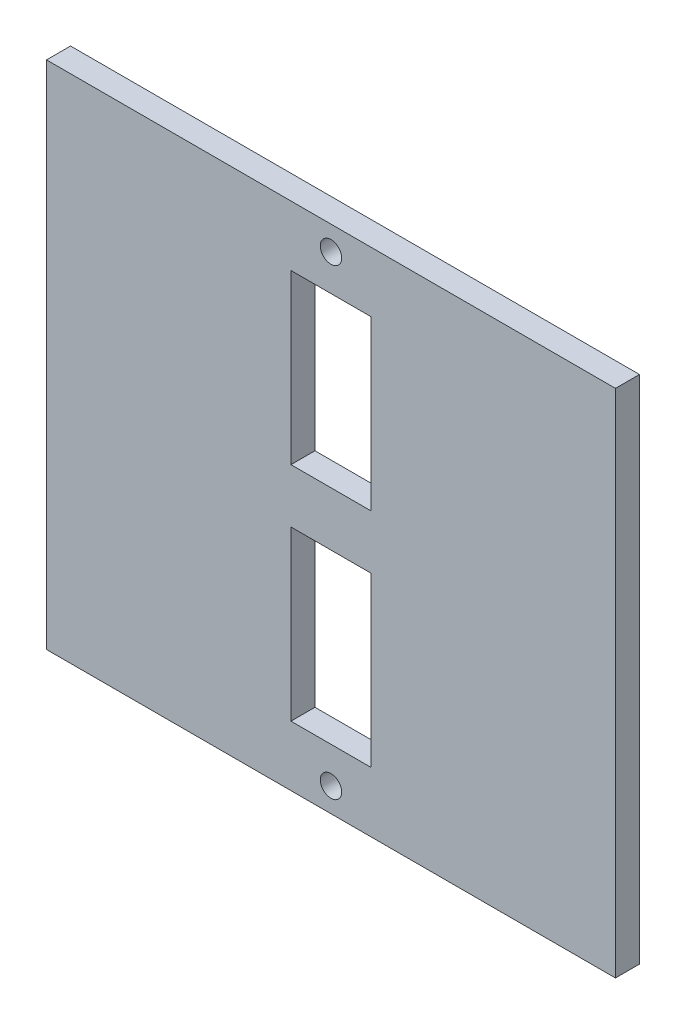
from build123d import *

# Parameters (mm, degrees)
SKETCH1_W           = 75.17
SKETCH1_H           = 67.47
SKETCH1_W_2         = 10.58
SKETCH1_H_2         = 22.218316852
BOSS_EXTRUDE1_DEPTH = 3.175
SKETCH2_R           = 1.415
CUT_EXTRUDE1_DEPTH  = 10


with BuildPart() as part:
    # Sketch1 → Boss-Extrude1 (new body)
    with BuildSketch(Plane.XY):
        Rectangle(SKETCH1_W, SKETCH1_H)
        with Locations((0, 14.675)):
            Rectangle(SKETCH1_W_2, SKETCH1_H_2, mode=Mode.SUBTRACT)
        with Locations((0, -14.675)):
            Rectangle(SKETCH1_W_2, SKETCH1_H_2, mode=Mode.SUBTRACT)
    extrude(amount=BOSS_EXTRUDE1_DEPTH)

    # Sketch2 → Cut-Extrude1 (cut)
    with BuildSketch(Plane.XY.offset(3.175)):
        with Locations((0, 30.553019485)):
            Circle(SKETCH2_R)
        with Locations((0, -30.553019485)):
            Circle(SKETCH2_R)
    extrude(amount=-CUT_EXTRUDE1_DEPTH, mode=Mode.SUBTRACT)


solid = part.part
